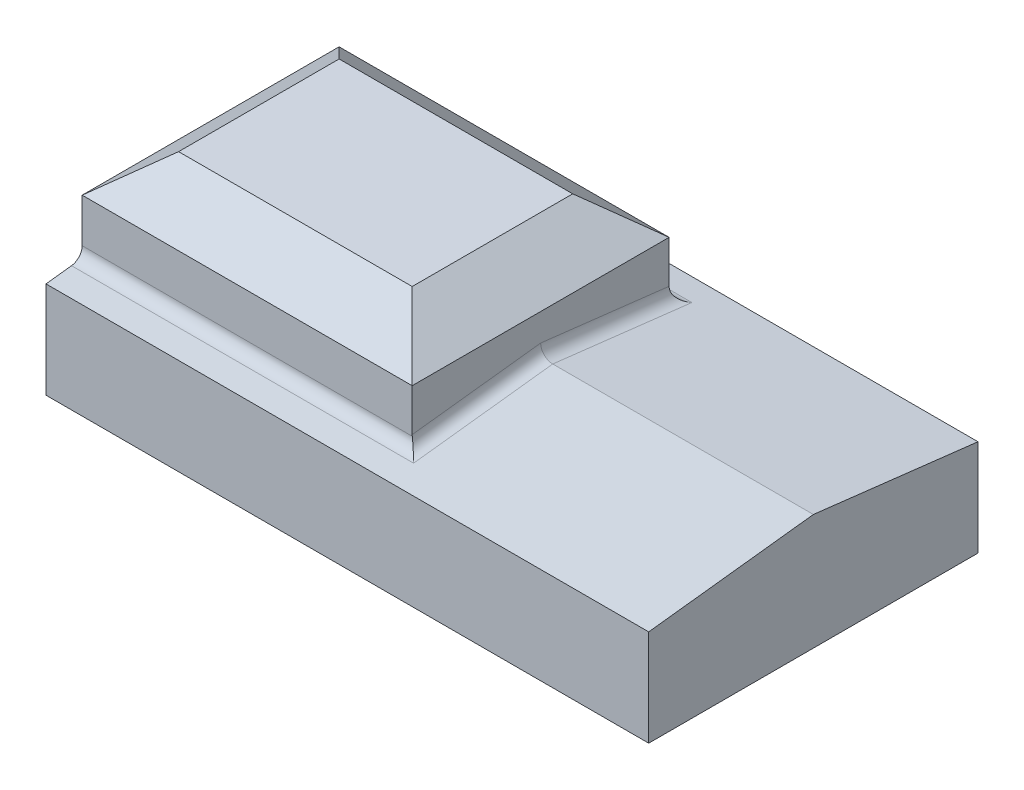
from build123d import *

# Parameters (mm, degrees)
SALIENTE_EXTRUIR1_DEPTH = 25
CROQUIS2_W              = 13.689149165
CROQUIS2_H              = 10.658244286
SALIENTE_EXTRUIR2_DEPTH = 8
REDONDEO1_R             = 0.5
CHAFL_N2_SIZE           = 2
CHAFL_N2_SIZE2          = 1.562571253
ESCALA2_SCALE           = 1.5
ESCALA3_SCALE           = 1.01
ESCALA4_SCALE           = 1.01
ESCALA5_SCALE           = 1.01


with BuildPart() as part:
    # Croquis1 → Saliente-Extruir1 (new body)
    with BuildSketch(Plane(origin=(0, 0, 0), x_dir=(0, 0, -1), z_dir=(1, 0, 0))):
        Polygon((6.829122143, 0), (-6.829122143, 0), (-6.829122143, 4), (0, 4.801857706), (6.829122143, 4), align=None)
    extrude(amount=SALIENTE_EXTRUIR1_DEPTH)

    # Croquis2 → Saliente-Extruir2 (add)
    with BuildSketch(Plane(origin=(0, 0, 0), x_dir=(1, 0, 0), z_dir=(0, 1, 0))):
        with Locations((6.844574583, 0)):
            Rectangle(CROQUIS2_W, CROQUIS2_H)
    extrude(amount=SALIENTE_EXTRUIR2_DEPTH)

    # Redondeo1
    redondeo1_edges = [part.edges().sort_by_distance(p)[0] for p in [
        (13.689149165, 4.488991896, 2.664561071),
        (13.689149165, 4.488991896, -2.664561071),
        (6.844574582, 4.176126087, 5.329122143),
        (6.844574582, 4.176126087, -5.329122143),
    ]]
    fillet(redondeo1_edges, radius=REDONDEO1_R)

    # Chaflán2
    chafl_n2_edges = [part.edges().sort_by_distance(p)[0] for p in [
        (0, 8, 0),
        (6.844574582, 8, 5.329122143),
        (13.689149165, 8, 0),
        (6.844574582, 8, -5.329122143),
    ]]
    chafl_n2_side = [part.faces().sort_by_distance(p)[0] for p in [
        (6.844574582, 8, 0),
    ]]
    chamfer(chafl_n2_edges, length=CHAFL_N2_SIZE, length2=CHAFL_N2_SIZE2, reference=chafl_n2_side[0])


with BuildPart() as part_1:
    # Escala2: scaled about (11.207296742, 3.085828341, 0)
    add(part.part.scale(ESCALA2_SCALE).moved(Location((-5.603648371, -1.542914171, 0))))


with BuildPart() as part_2:
    # Escala3: scaled about (11.207296743, 3.085828341, 0)
    add(part_1.part.scale(ESCALA3_SCALE).moved(Location((-0.112072967, -0.030858283, 0))))


with BuildPart() as part_3:
    # Escala4: scaled about (11.207296743, 3.085828341, 0)
    add(part_2.part.scale(ESCALA4_SCALE).moved(Location((-0.112072967, -0.030858283, 0))))


with BuildPart() as part_4:
    # Escala5: scaled about (11.207296743, 3.085828341, 0)
    add(part_3.part.scale(ESCALA5_SCALE).moved(Location((-0.112072967, -0.030858283, 0))))


solid = part_4.part
